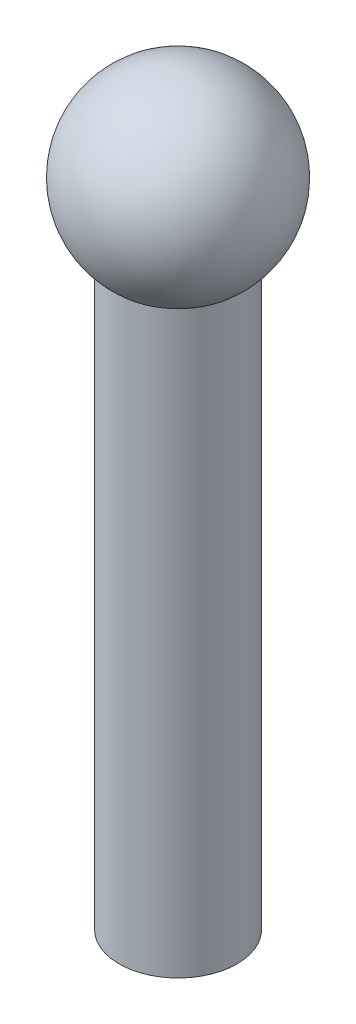
from build123d import *

# Parameters (mm, degrees)
SKETCH2_R           = 4.755
BOSS_EXTRUDE1_DEPTH = 3
SKETCH3_R           = 4.755
BOSS_EXTRUDE2_DEPTH = 45


with BuildPart() as part:
    # Sketch1 → Revolve1 (revolve)
    with BuildSketch(Plane.XY):
        with BuildLine():
            Line((0, 0), (0, 15))
            ThreePointArc((0, 15), (-7.5, 7.5), (0, 0))
        make_face()
    revolve(axis=Axis((0, 0, 0), (0, 1, 0)))

    # Sketch2 → Boss-Extrude1 (add)
    with BuildSketch(Plane(origin=(0, 0, 0), x_dir=(-1, 0, 0), z_dir=(0, -1, 0))):
        Circle(SKETCH2_R)
    extrude(amount=-BOSS_EXTRUDE1_DEPTH)

    # Sketch3 → Boss-Extrude2 (add)
    with BuildSketch(Plane(origin=(0, 0, 0), x_dir=(-1, 0, 0), z_dir=(0, -1, 0))):
        Circle(SKETCH3_R)
    extrude(amount=BOSS_EXTRUDE2_DEPTH)


solid = part.part
